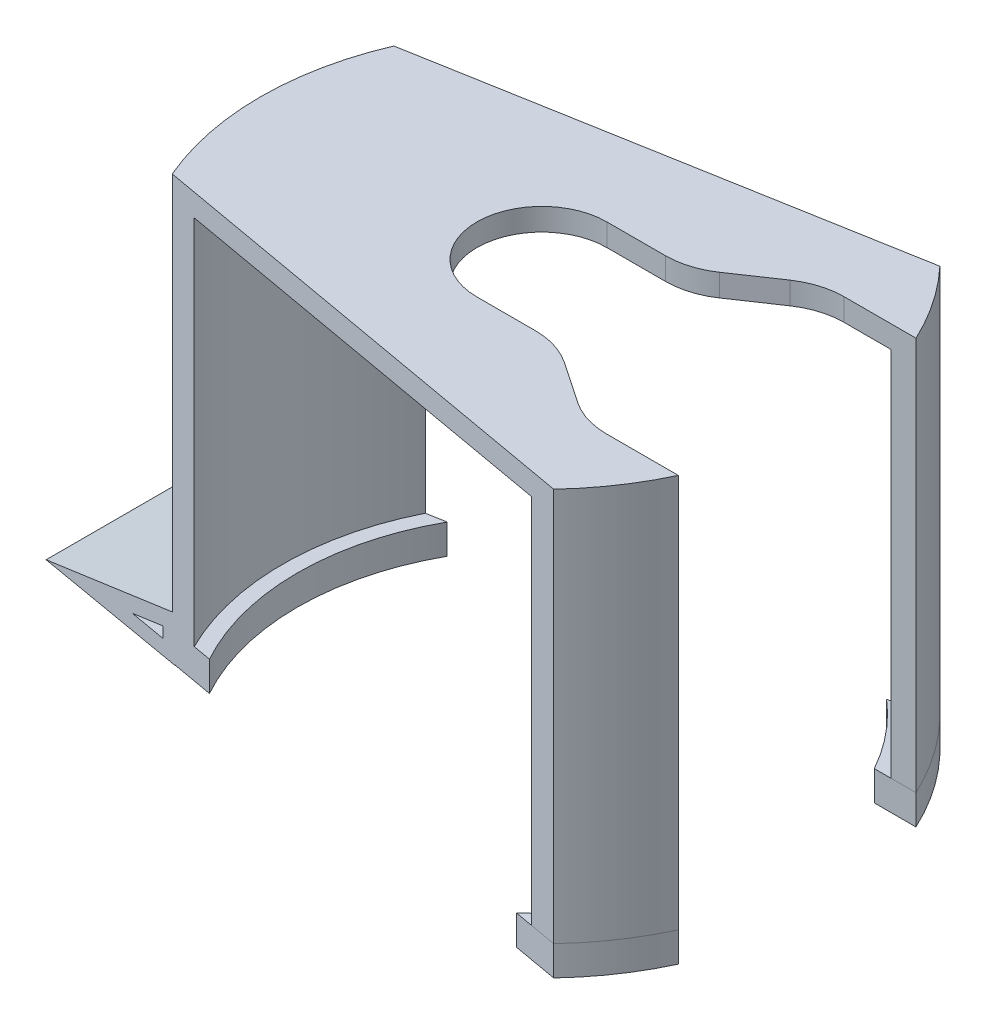
from build123d import *
from build123d.topology import SkipClean

# Parameters (mm, degrees)
BOSS_EXTRUDE1_DEPTH   = 50
BOSS_EXTRUDE1_2_DEPTH = 50
BOSS_EXTRUDE1_3_DEPTH = 50
BOSS_EXTRUDE2_START   = -4
BOSS_EXTRUDE2_DEPTH   = 4
BOSS_EXTRUDE3_START   = -32
BOSS_EXTRUDE3_DEPTH   = 32
CUT_EXTRUDE1_DEPTH    = 58
BOSS_EXTRUDE4_DEPTH   = 3
SKETCH6_R             = 34.91
CUT_EXTRUDE2_DEPTH    = 10


with BuildPart() as part:
    # Sketch1 → Boss-Extrude1 (new body)
    with BuildSketch(Plane(origin=(0, 0, 0), x_dir=(1, 0, 0), z_dir=(0, 1, 0))):
        with BuildLine():
            Line((-31.027537769, 16), (-34.368126222, 16))
            ThreePointArc((-34.368126222, 16), (-37.91, 0), (-34.368126222, -16))
            Line((-34.368126222, -16), (-31.027537769, -16))
            ThreePointArc((-31.027537769, -16), (-34.91, 0), (-31.027537769, 16))
        make_face()
    extrude(amount=BOSS_EXTRUDE1_DEPTH)

    # Sketch2 → Boss-Extrude2 (add)
    with BuildSketch(Plane(origin=(0, 0, 0), x_dir=(1, 0, 0), z_dir=(0, 1, 0)).offset(BOSS_EXTRUDE2_START)):
        with BuildLine():
            Line((28.758791699, 16), (34.368126222, 16))
            ThreePointArc((34.368126222, 16), (31.379609531, 21.271770158), (27.58927509, 26))
            Line((27.58927509, 26), (20.175928727, 26))
            ThreePointArc((20.175928727, 26), (24.973019757, 21.434000658), (28.758791699, 16))
        make_face()
        with BuildLine():
            ThreePointArc((-28.758791699, -16), (-32.91, 0), (-28.758791699, 16))
            Line((-28.758791699, 16), (-34.368126222, 16))
            ThreePointArc((-34.368126222, 16), (-37.91, 0), (-34.368126222, -16))
            Line((-34.368126222, -16), (-28.758791699, -16))
        make_face()
        with BuildLine():
            ThreePointArc((27.58927509, -26), (31.379609531, -21.271770158), (34.368126222, -16))
            Line((34.368126222, -16), (28.758791699, -16))
            ThreePointArc((28.758791699, -16), (24.973019757, -21.434000658), (20.175928727, -26))
            Line((20.175928727, -26), (27.58927509, -26))
        make_face()
    extrude(amount=BOSS_EXTRUDE2_DEPTH)


with BuildPart() as body_2:
    # Sketch1 → Boss-Extrude1 2 (new body)
    with BuildSketch(Plane(origin=(0, 0, 0), x_dir=(1, 0, 0), z_dir=(0, 1, 0))):
        with BuildLine():
            ThreePointArc((34.368126222, 16), (31.379609531, 21.271770158), (27.58927509, 26))
            Line((27.58927509, 26), (23.296096239, 26))
            ThreePointArc((23.296096239, 26), (27.618187902, 21.352840491), (31.027537769, 16))
            Line((31.027537769, 16), (34.368126222, 16))
        make_face()
    extrude(amount=BOSS_EXTRUDE1_2_DEPTH)


with BuildPart() as body_3:
    # Sketch1 → Boss-Extrude1 3 (new body)
    with BuildSketch(Plane(origin=(0, 0, 0), x_dir=(1, 0, 0), z_dir=(0, 1, 0))):
        with BuildLine():
            Line((23.296096239, -26), (27.58927509, -26))
            ThreePointArc((27.58927509, -26), (31.379609531, -21.271770158), (34.368126222, -16))
            Line((34.368126222, -16), (31.027537769, -16))
            ThreePointArc((31.027537769, -16), (27.618187902, -21.352840491), (23.296096239, -26))
        make_face()
    extrude(amount=BOSS_EXTRUDE1_3_DEPTH)


with BuildPart() as boss_extrude2_piece_1:
    # of the separate pieces the step leaves, piece 1, a body of its own (boss_extrude2_pieces)
    add(part.part.solids().sort_by_distance((-31.027537769, 0, 16))[0])

    # Sketch3 → Boss-Extrude3 (add)
    with BuildSketch(Plane.XY.offset(16).offset(BOSS_EXTRUDE3_START)):
        Polygon((-34.368126222, -4.048268878), (-55.498786824, -4.145046738), (-34.368126222, 2.073247191), align=None)
        Polygon((-36.368126222, -2.057407848), (-41.398520838, -2.080446921), (-36.368126222, -0.600111172), align=None, mode=Mode.SUBTRACT)
    extrude(amount=BOSS_EXTRUDE3_DEPTH)


with BuildPart() as boss_extrude2_piece_2:
    # of the separate pieces the step leaves, piece 2, a body of its own (boss_extrude2_pieces)
    add(part.part.solids().sort_by_distance((28.758791699, -4, -16))[0])


with BuildPart() as boss_extrude2_piece_3:
    # of the separate pieces the step leaves, piece 3, a body of its own (boss_extrude2_pieces)
    add(part.part.solids().sort_by_distance((28.758791699, -4, 16))[0])


with BuildPart() as cut_extrude1_tool:
    # Sketch4 → Cut-Extrude1 (new body)
    with BuildSketch(Plane(origin=(0, 50, 0), x_dir=(1, 0, 0), z_dir=(0, 1, 0))):
        Polygon((27.58927509, 26), (-55.498786824, 11.254496445), (-55.498786824, -11.254496445), (27.58927509, -26), (27.58927509, -30.815514941), (-65.642011764, -30.815514941), (-65.073155403, 32.733867097), (27.58927509, 31.904408001), align=None)
    extrude(amount=-CUT_EXTRUDE1_DEPTH)


with BuildPart() as body_2_1:
    add(body_2.part)

    # Cut-Extrude1: cut by cut_extrude1_tool
    add(cut_extrude1_tool.part, mode=Mode.SUBTRACT)



with BuildPart() as body_3_1:
    add(body_3.part)

    # Cut-Extrude1: cut by cut_extrude1_tool
    add(cut_extrude1_tool.part, mode=Mode.SUBTRACT)


with BuildPart() as boss_extrude2_piece_1_1:
    add(boss_extrude2_piece_1.part)

    # Cut-Extrude1: cut by cut_extrude1_tool
    add(cut_extrude1_tool.part, mode=Mode.SUBTRACT)


with BuildPart() as boss_extrude2_piece_2_1:
    add(boss_extrude2_piece_2.part)

    # Cut-Extrude1: cut by cut_extrude1_tool
    add(cut_extrude1_tool.part, mode=Mode.SUBTRACT)


with BuildPart() as boss_extrude2_piece_3_1:
    add(boss_extrude2_piece_3.part)

    # Cut-Extrude1: cut by cut_extrude1_tool
    add(cut_extrude1_tool.part, mode=Mode.SUBTRACT)


with BuildPart() as body_2_2:
    add(body_2_1.part)

    add(body_3_1.part)  # Boss-Extrude4 merges body 3

    add(boss_extrude2_piece_1_1.part)  # Boss-Extrude4 merges Boss-Extrude2 piece 1
    # Sketch5 → Boss-Extrude4 (add)
    with BuildSketch(Plane(origin=(0, 50, 0), x_dir=(1, 0, 0), z_dir=(0, 1, 0))):
        with BuildLine():
            Line((0, 8.75), (7.868608219, 8.75))
            ThreePointArc((7.868608219, 8.75), (10.800561485, 9.189474384), (13.474811079, 10.46926999))
            Line((13.474811079, 10.46926999), (19.104587981, 14.28073001))
            ThreePointArc((19.104587981, 14.28073001), (21.778837575, 15.560525616), (24.710790841, 16))
            Line((24.710790841, 16), (34.368126222, 16))
            ThreePointArc((34.368126222, 16), (31.379609531, 21.271770158), (27.58927509, 26))
            Line((27.58927509, 26), (-34.851070481, 14.918813168))
            ThreePointArc((-34.851070481, 14.918813168), (-37.91, 0), (-34.851070481, -14.918813168))
            Line((-34.851070481, -14.918813168), (27.58927509, -26))
            ThreePointArc((27.58927509, -26), (31.379609531, -21.271770158), (34.368126222, -16))
            Line((34.368126222, -16), (24.710790841, -16))
            ThreePointArc((24.710790841, -16), (21.778837575, -15.560525616), (19.104587981, -14.28073001))
            Line((19.104587981, -14.28073001), (13.474811079, -10.46926999))
            ThreePointArc((13.474811079, -10.46926999), (10.800561485, -9.189474384), (7.868608219, -8.75))
            Line((7.868608219, -8.75), (0, -8.75))
            ThreePointArc((0, -8.75), (-8.75, 0), (0, 8.75))
        make_face()
    extrude(amount=BOSS_EXTRUDE4_DEPTH)

    # Sketch6 → Cut-Extrude2 (cut)
    with SkipClean():  # the faces are left unmerged after this step: merging them gives an invalid solid
        with BuildSketch(Plane(origin=(0, 0, 0), x_dir=(1, 0, 0), z_dir=(0, 1, 0))):
            Circle(SKETCH6_R)
        extrude(amount=CUT_EXTRUDE2_DEPTH, mode=Mode.SUBTRACT)


solid = Compound([boss_extrude2_piece_2_1.part, boss_extrude2_piece_3_1.part, body_2_2.part])
